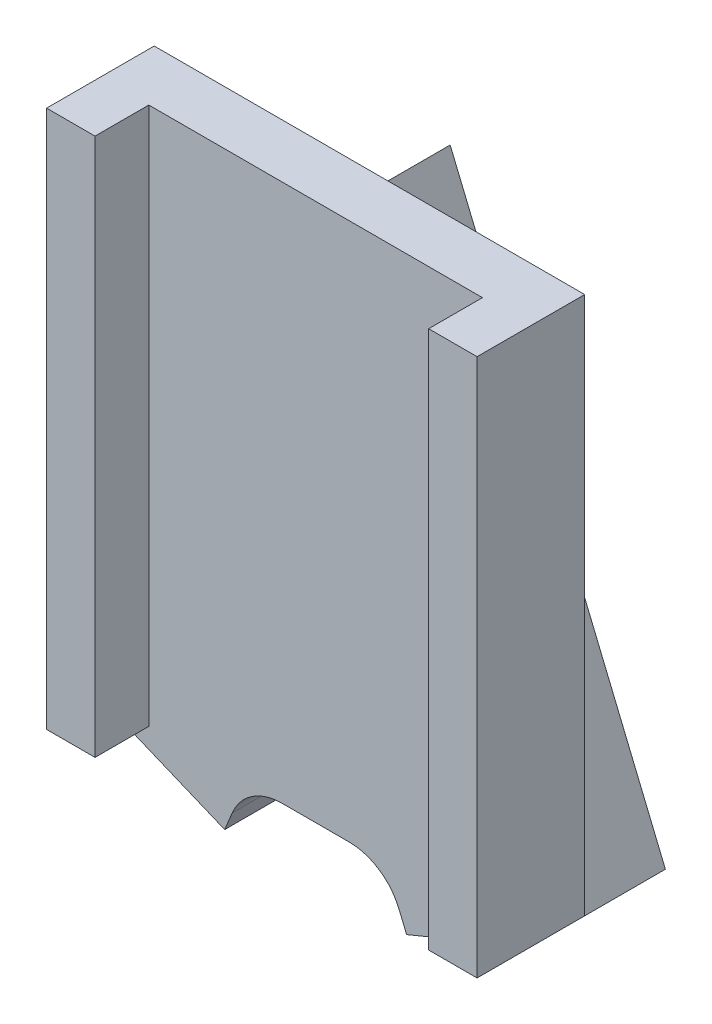
from build123d import *

# Parameters (mm, degrees)
SKETCH1_W                = 8
SKETCH1_H                = 10
BOSS_EXTRUDE1_DEPTH      = 2
SKETCH2_W                = 6.2
SKETCH2_H                = 10
CUT_EXTRUDE1_DEPTH       = 1
BOSS_EXTRUDE2_DEPTH      = 1.5
BOSS_EXTRUDE2_DEPTH_BACK = 1
M1_CLEARANCE_HOLE2_D     = 1.2
M1_CLEARANCE_HOLE2_DEPTH = 5
M1_CLEARANCE_HOLE2_TIP   = 0.360516371
M1_CLEARANCE_HOLE1_D     = 1
M1_CLEARANCE_HOLE1_DEPTH = 5
M1_CLEARANCE_HOLE1_TIP   = 0.30043031
SKETCH8_R                = 0.4
CUT_EXTRUDE2_DEPTH       = 1.5
FILLET2_R                = 1


with BuildPart() as part:
    # Sketch1 → Boss-Extrude1 (new body)
    with BuildSketch(Plane.XY):
        with Locations((4, -5)):
            Rectangle(SKETCH1_W, SKETCH1_H)
    extrude(amount=BOSS_EXTRUDE1_DEPTH)

    # Sketch2 → Cut-Extrude1 (cut)
    with BuildSketch(Plane.XY.offset(2)):
        with Locations((4, -5)):
            Rectangle(SKETCH2_W, SKETCH2_H)
    extrude(amount=-CUT_EXTRUDE1_DEPTH, mode=Mode.SUBTRACT)

    # Sketch3 → Boss-Extrude2 (add, two sides)
    with BuildSketch(Plane(origin=(0, 0, 0), x_dir=(-1, 0, 0), z_dir=(0, 0, -1))) as boss_extrude2_sk:
        Polygon((-8, -10), (-4, -0.343145751), (0, -10), (-2.309698831, -10.956708581), (-4, -6.875960575), (-5.690301169, -10.956708581), align=None)
    extrude(amount=BOSS_EXTRUDE2_DEPTH)
    extrude(boss_extrude2_sk.sketch, amount=-BOSS_EXTRUDE2_DEPTH_BACK)

    # M1 Clearance Hole2
    with Locations(Plane(origin=(-3.535533906, -8.535533906, 0), x_dir=(-0.923879533, 0.382683432, 0), z_dir=(-0.382683432, -0.923879533, 0))):
        with Locations((-5.115994416, 0.25)):
            Hole(M1_CLEARANCE_HOLE2_D / 2, depth=M1_CLEARANCE_HOLE2_DEPTH)
            with Locations((0, 0, -(M1_CLEARANCE_HOLE2_DEPTH + M1_CLEARANCE_HOLE2_TIP / 2))):  # 118° drill point
                Cone(0, M1_CLEARANCE_HOLE2_D / 2, M1_CLEARANCE_HOLE2_TIP, mode=Mode.SUBTRACT)

    # M1 Clearance Hole1
    with Locations(Plane(origin=(4.707106781, -11.363961031, 0), x_dir=(-0.923879533, -0.382683432, 0), z_dir=(0.382683432, -0.923879533, 0))):
        with Locations((-2.314201936, 0.25)):
            Hole(M1_CLEARANCE_HOLE1_D / 2, depth=M1_CLEARANCE_HOLE1_DEPTH)
            with Locations((0, 0, -(M1_CLEARANCE_HOLE1_DEPTH + M1_CLEARANCE_HOLE1_TIP / 2))):  # 118° drill point
                Cone(0, M1_CLEARANCE_HOLE1_D / 2, M1_CLEARANCE_HOLE1_TIP, mode=Mode.SUBTRACT)

    # Sketch8 → Cut-Extrude2 (cut)
    with BuildSketch(Plane(origin=(0, 0, -1.5), x_dir=(-1, 0, 0), z_dir=(0, 0, -1))):
        with Locations((-4, -7.3)):
            Circle(SKETCH8_R)
    extrude(amount=-CUT_EXTRUDE2_DEPTH, mode=Mode.SUBTRACT)

    # Fillet2
    fillet2_edges = [part.edges().sort_by_distance(p)[0] for p in [
        (2.705980501, -10, 0.5),
        (5.294019499, -10, 0.5),
    ]]
    fillet(fillet2_edges, radius=FILLET2_R)


solid = part.part
